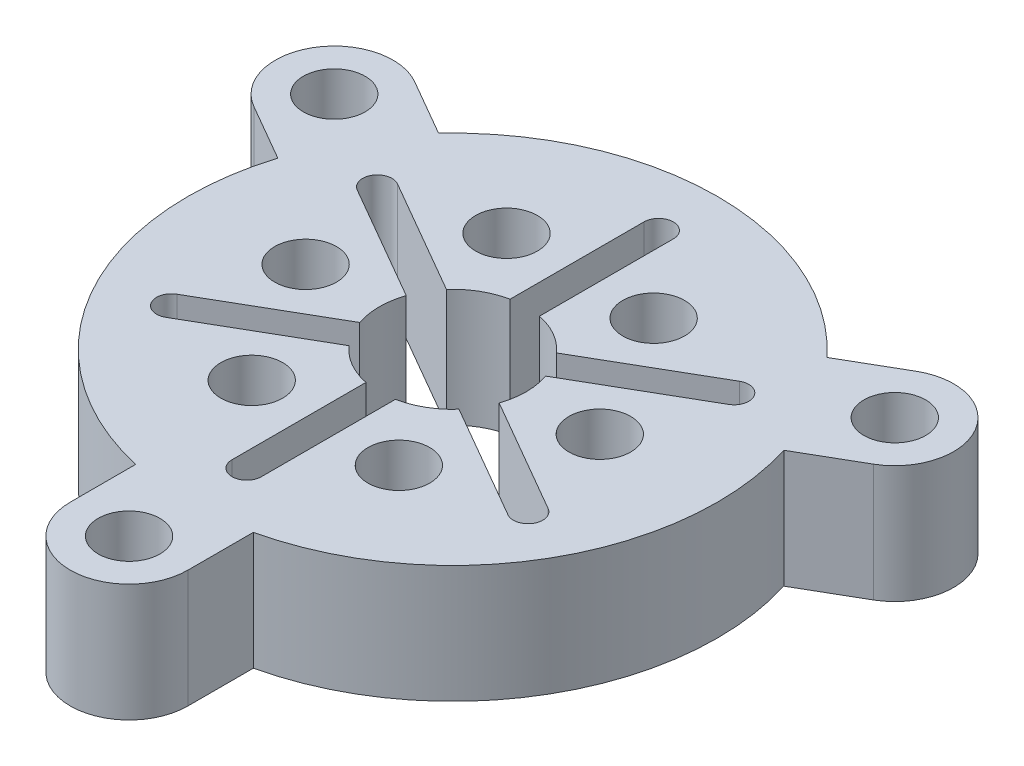
from build123d import *

# Parameters (mm, degrees)
SKETCH1_R           = 2.1
BOSS_EXTRUDE1_DEPTH = 8
SKETCH2_R           = 2.1
CUT_EXTRUDE1_DEPTH  = 5.8


with BuildPart() as part:
    # Sketch1 → Boss-Extrude1 (new body)
    with BuildSketch(Plane(origin=(0, 0, 0), x_dir=(1, 0, 0), z_dir=(0, 1, 0))):
        with BuildLine():
            Line((-4, -22), (-4, -17.549928775))
            ThreePointArc((-4, -17.549928775), (-15.588457268, -9), (-17.198684154, 5.310862772))
            Line((-17.198684154, 5.310862772), (-21.052558883, 7.535898385))
            ThreePointArc((-21.052558883, 7.535898385), (-22.516660498, 13), (-17.052558883, 14.464101615))
            Line((-17.052558883, 14.464101615), (-13.198684154, 12.239066003))
            ThreePointArc((-13.198684154, 12.239066003), (0, 18), (13.198684154, 12.239066003))
            Line((13.198684154, 12.239066003), (17.052558883, 14.464101615))
            ThreePointArc((17.052558883, 14.464101615), (22.516660498, 13), (21.052558883, 7.535898385))
            Line((21.052558883, 7.535898385), (17.198684154, 5.310862772))
            ThreePointArc((17.198684154, 5.310862772), (15.588457268, -9), (4, -17.549928775))
            Line((4, -17.549928775), (4, -22))
            ThreePointArc((4, -22), (0, -26), (-4, -22))
        make_face()
        with Locations((0, -22)):
            Circle(SKETCH1_R, mode=Mode.SUBTRACT)
        with Locations((-19.052558883, 11)):
            Circle(SKETCH1_R, mode=Mode.SUBTRACT)
        with Locations((19.052558883, 11)):
            Circle(SKETCH1_R, mode=Mode.SUBTRACT)
        with BuildLine():
            Line((1, 4.898979486), (1, 14))
            ThreePointArc((1, 14), (0, 15), (-1, 14))
            Line((-1, 14), (-1, 4.898979486))
            ThreePointArc((-1, 4.898979486), (-2.5, 4.330127019), (-3.742640687, 3.315515147))
            Line((-3.742640687, 3.315515147), (-11.624355653, 7.866025404))
            ThreePointArc((-11.624355653, 7.866025404), (-12.990381057, 7.5), (-12.624355653, 6.133974596))
            Line((-12.624355653, 6.133974596), (-4.742640687, 1.583464339))
            ThreePointArc((-4.742640687, 1.583464339), (-5, 0), (-4.742640687, -1.583464339))
            Line((-4.742640687, -1.583464339), (-12.624355653, -6.133974596))
            ThreePointArc((-12.624355653, -6.133974596), (-12.990381057, -7.5), (-11.624355653, -7.866025404))
            Line((-11.624355653, -7.866025404), (-3.742640687, -3.315515147))
            ThreePointArc((-3.742640687, -3.315515147), (-2.5, -4.330127019), (-1, -4.898979486))
            Line((-1, -4.898979486), (-1, -14))
            ThreePointArc((-1, -14), (0, -15), (1, -14))
            Line((1, -14), (1, -4.898979486))
            ThreePointArc((1, -4.898979486), (2.5, -4.330127019), (3.742640687, -3.315515147))
            Line((3.742640687, -3.315515147), (11.624355653, -7.866025404))
            ThreePointArc((11.624355653, -7.866025404), (12.990381057, -7.5), (12.624355653, -6.133974596))
            Line((12.624355653, -6.133974596), (4.742640687, -1.583464339))
            ThreePointArc((4.742640687, -1.583464339), (5, 0), (4.742640687, 1.583464339))
            Line((4.742640687, 1.583464339), (12.624355653, 6.133974596))
            ThreePointArc((12.624355653, 6.133974596), (12.990381057, 7.5), (11.624355653, 7.866025404))
            Line((11.624355653, 7.866025404), (3.742640687, 3.315515147))
            ThreePointArc((3.742640687, 3.315515147), (2.5, 4.330127019), (1, 4.898979486))
        make_face(mode=Mode.SUBTRACT)
    extrude(amount=BOSS_EXTRUDE1_DEPTH)

    # Sketch2 → Cut-Extrude1 (cut)
    with BuildSketch(Plane(origin=(0, 8, 0), x_dir=(1, 0, 0), z_dir=(0, 1, 0))):
        with Locations((10, 0)):
            Circle(SKETCH2_R)
        with Locations((5, -8.660254038)):
            Circle(SKETCH2_R)
        with Locations((-5, -8.660254038)):
            Circle(SKETCH2_R)
        with Locations((-10, 0)):
            Circle(SKETCH2_R)
        with Locations((-5, 8.660254038)):
            Circle(SKETCH2_R)
        with Locations((5, 8.660254038)):
            Circle(SKETCH2_R)
    extrude(amount=-CUT_EXTRUDE1_DEPTH, mode=Mode.SUBTRACT)


solid = part.part
